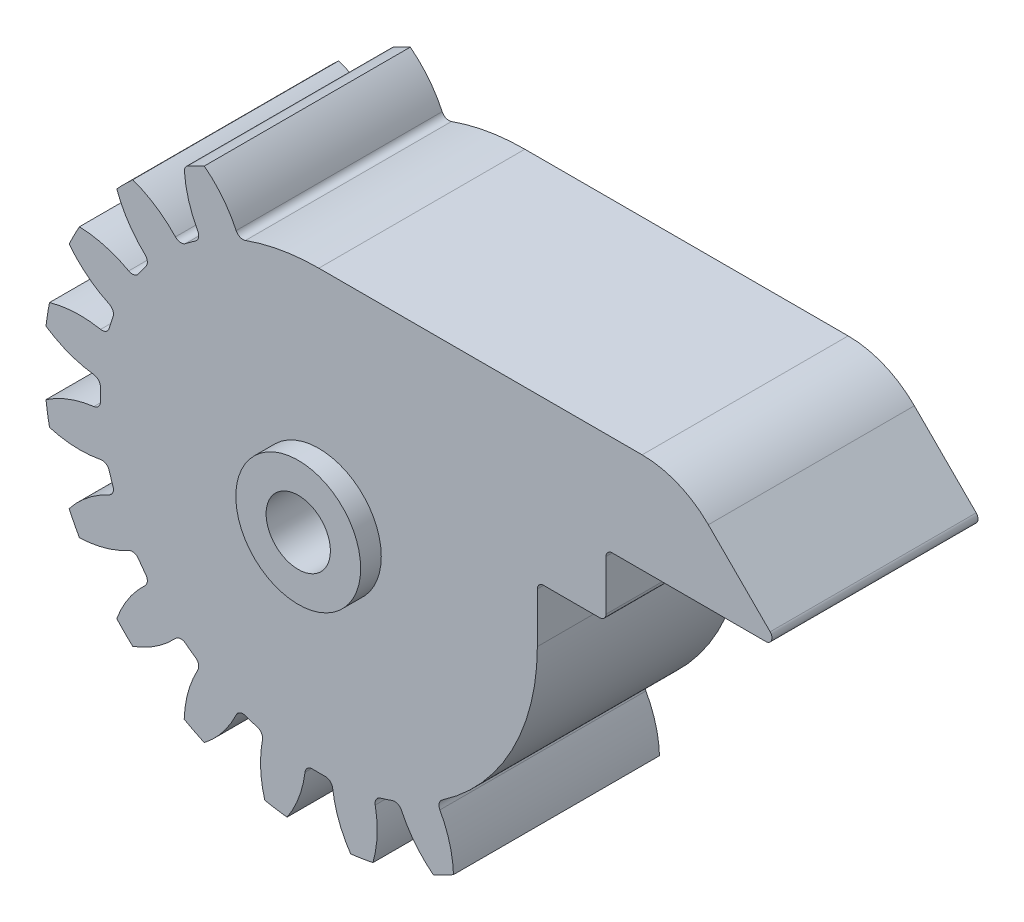
from build123d import *

# Parameters (mm, degrees)
SKBASE_R                                = 22
BASE_DEPTH                              = 8.25
TOOTHPROFILE_DEPTH                      = 9.25
FILLETTOOTHPROFILE_R                    = 0.6
CIRPATTERNTEETH_COUNT                   = 20
FILLETTOOTHPROFILE_OF_CIRPATTERNTEETH_R = 0.6
SKCHAVETA_R                             = 2.575
CHAVETA_DEPTH                           = 17.5000001
CUT_EXTRUDE1_DEPTH                      = 16.5
BOSS_EXTRUDE1_DEPTH                     = 16.5
FILLET3_R                               = 0.5
BOSS_EXTRUDE2_START                     = -16.5
SKETCH10_R                              = 5
SKETCH10_R_2                            = 2.575
BOSS_EXTRUDE2_DEPTH                     = 1.65
FILLET4_R                               = 7.5


with BuildPart() as part:
    # skBase → Base (new body, symmetric)
    with BuildSketch(Plane.XY):
        Circle(SKBASE_R)
    extrude(amount=BASE_DEPTH, both=True)

    # skToothProfile → ToothProfile (cut, symmetric)
    with BuildSketch(Plane.XY):
        with BuildLine():
            ThreePointArc((-1.056260379, 17.468094172), (-1.711312383, 20.303280592), (-3.25795804, 22.768085326))
            ThreePointArc((-3.25795804, 22.768085326), (0, 23), (3.25795804, 22.768085326))
            ThreePointArc((3.25795804, 22.768085326), (1.711312383, 20.303280592), (1.056260379, 17.468094172))
            ThreePointArc((1.056260379, 17.468094172), (0, 17.5), (-1.056260379, 17.468094172))
        make_face()
    toothprofile = extrude(amount=TOOTHPROFILE_DEPTH, both=True, mode=Mode.SUBTRACT)

    # FilletToothProfile
    fillettoothprofile_edges = [part.edges().sort_by_distance(p)[0] for p in [
        (-1.056260379, 17.468094172, 0),
        (1.056260379, 17.468094172, 0),
    ]]
    fillet(fillettoothprofile_edges, radius=FILLETTOOTHPROFILE_R)

    # CirPatternTeeth: ToothProfile ×20 about axis
    cirpatternteeth_axis = Axis((0, 0, 0), (0, 0, 1))
    for i in range(1, CIRPATTERNTEETH_COUNT):
        add(toothprofile.rotate(cirpatternteeth_axis, i * 360 / CIRPATTERNTEETH_COUNT), mode=Mode.SUBTRACT)

    # FilletToothProfile of CirPatternTeeth
    fillettoothprofile_of_cirpatternteeth_edges = [part.edges().sort_by_distance(p)[0] for p in [
        (-6.402501275, 16.286742382, 0),
        (-4.393374642, 16.939547198, 0),
        (-11.122020738, 13.511130771, 0),
        (-9.412955543, 14.752839318, 0),
        (-14.752839318, 9.412955543, 0),
        (-13.511130771, 11.122020738, 0),
        (-16.939547198, 4.393374642, 0),
        (-16.286742382, 6.402501275, 0),
        (-17.468094172, -1.056260379, 0),
        (-17.468094172, 1.056260379, 0),
        (-16.286742382, -6.402501275, 0),
        (-16.939547198, -4.393374642, 0),
        (-13.511130771, -11.122020738, 0),
        (-14.752839318, -9.412955543, 0),
        (-9.412955543, -14.752839318, 0),
        (-11.122020738, -13.511130771, 0),
        (-4.393374642, -16.939547198, 0),
        (-6.402501275, -16.286742382, 0),
        (1.056260379, -17.468094172, 0),
        (-1.056260379, -17.468094172, 0),
        (6.402501275, -16.286742382, 0),
        (4.393374642, -16.939547198, 0),
        (11.122020738, -13.511130771, 0),
        (9.412955543, -14.752839318, 0),
        (14.752839318, -9.412955543, 0),
        (13.511130771, -11.122020738, 0),
        (16.939547198, -4.393374642, 0),
        (16.286742382, -6.402501275, 0),
        (17.468094172, 1.056260379, 0),
        (17.468094172, -1.056260379, 0),
        (16.286742382, 6.402501275, 0),
        (16.939547198, 4.393374642, 0),
        (13.511130771, 11.122020738, 0),
        (14.752839318, 9.412955543, 0),
        (9.412955543, 14.752839318, 0),
        (11.122020738, 13.511130771, 0),
        (4.393374642, 16.939547198, 0),
        (6.402501275, 16.286742382, 0),
    ]]
    fillet(fillettoothprofile_of_cirpatternteeth_edges, radius=FILLETTOOTHPROFILE_OF_CIRPATTERNTEETH_R)

    # skChaveta → Chaveta (cut, through all)
    with BuildSketch(Plane.XY.offset(8.25)):
        Circle(SKCHAVETA_R)
    extrude(amount=-CHAVETA_DEPTH, mode=Mode.SUBTRACT)

    # Sketch7 → Cut-Extrude1 (cut)
    with BuildSketch(Plane(origin=(0, 0, -8.25), x_dir=(-1, 0, 0), z_dir=(0, 0, -1))):
        with BuildLine():
            ThreePointArc((-17.493007874, 0.494646854), (-17.28454596, 2.737603138), (-16.789693413, 4.935199602))
            ThreePointArc((-16.789693413, 4.935199602), (-17.05320753, 4.591987385), (-17.479060308, 4.515281924))
            ThreePointArc((-17.479060308, 4.515281924), (-19.535104209, 4.665405011), (-21.569390736, 4.331441248))
            ThreePointArc((-21.569390736, 4.331441248), (-21.729143493, 3.441558231), (-21.852198568, 2.545862871))
            ThreePointArc((-21.852198568, 2.545862871), (-20.020677589, 1.599615351), (-18.018873054, 1.107038384))
            ThreePointArc((-18.018873054, 1.107038384), (-17.637566285, 0.90249141), (-17.493007874, 0.494646854))
        make_face()
        with BuildLine():
            ThreePointArc((-17.479060308, -4.515281924), (-17.05320753, -4.591987385), (-16.789693413, -4.935199602))
            ThreePointArc((-16.789693413, -4.935199602), (-17.28454596, -2.737603138), (-17.493007874, -0.494646854))
            ThreePointArc((-17.493007874, -0.494646854), (-17.637566285, -0.90249141), (-18.018873054, -1.107038384))
            ThreePointArc((-18.018873054, -1.107038384), (-20.020677589, -1.599615351), (-21.852198568, -2.545862871))
            ThreePointArc((-21.852198568, -2.545862871), (-21.729143493, -3.441558231), (-21.569390736, -4.331441248))
            ThreePointArc((-21.569390736, -4.331441248), (-19.535104209, -4.665405011), (-17.479060308, -4.515281924))
        make_face()
        with BuildLine():
            ThreePointArc((-15.228275356, -9.695614978), (-14.799562005, -9.636970461), (-14.442886779, -9.881954336))
            ThreePointArc((-14.442886779, -9.881954336), (-15.592614173, -7.944833745), (-16.483984844, -5.87607383))
            ThreePointArc((-16.483984844, -5.87607383), (-16.495437164, -6.308628058), (-16.79487296, -6.620994062))
            ThreePointArc((-16.79487296, -6.620994062), (-18.546487554, -7.708054217), (-19.99596095, -9.173960195))
            ThreePointArc((-19.99596095, -9.173960195), (-19.602143532, -9.987790994), (-19.175220656, -10.78475372))
            ThreePointArc((-19.175220656, -10.78475372), (-17.137298721, -10.473743024), (-15.228275356, -9.695614978))
        make_face()
        with BuildLine():
            ThreePointArc((-16.483984844, 5.87607383), (-15.592614173, 7.944833745), (-14.442886779, 9.881954336))
            ThreePointArc((-14.442886779, 9.881954336), (-14.799562005, 9.636970461), (-15.228275356, 9.695614978))
            ThreePointArc((-15.228275356, 9.695614978), (-17.137298721, 10.473743024), (-19.175220656, 10.78475372))
            ThreePointArc((-19.175220656, 10.78475372), (-19.602143532, 9.987790994), (-19.99596095, 9.173960195))
            ThreePointArc((-19.99596095, 9.173960195), (-18.546487554, 7.708054217), (-16.79487296, 6.620994062))
            ThreePointArc((-16.79487296, 6.620994062), (-16.495437164, 6.308628058), (-16.483984844, 5.87607383))
        make_face()
        with BuildLine():
            ThreePointArc((-13.861394527, 10.682309758), (-12.374368671, 12.374368671), (-10.682309758, 13.861394527))
            ThreePointArc((-10.682309758, 13.861394527), (-11.097232237, 13.738619723), (-11.48684071, 13.926873684))
            ThreePointArc((-11.48684071, 13.926873684), (-13.061975031, 15.256838096), (-14.904046377, 16.182379355))
            ThreePointArc((-14.904046377, 16.182379355), (-15.556349186, 15.556349186), (-16.182379355, 14.904046377))
            ThreePointArc((-16.182379355, 14.904046377), (-15.256838096, 13.061975031), (-13.926873684, 11.48684071))
            ThreePointArc((-13.926873684, 11.48684071), (-13.738619723, 11.097232237), (-13.861394527, 10.682309758))
        make_face()
        with BuildLine():
            ThreePointArc((-9.881954336, 14.442886779), (-7.944833745, 15.592614173), (-5.87607383, 16.483984844))
            ThreePointArc((-5.87607383, 16.483984844), (-6.308628058, 16.495437164), (-6.620994062, 16.79487296))
            ThreePointArc((-6.620994062, 16.79487296), (-7.708054217, 18.546487554), (-9.173960195, 19.99596095))
            ThreePointArc((-9.173960195, 19.99596095), (-9.987790994, 19.602143532), (-10.78475372, 19.175220656))
            ThreePointArc((-10.78475372, 19.175220656), (-10.473743024, 17.137298721), (-9.695614978, 15.228275356))
            ThreePointArc((-9.695614978, 15.228275356), (-9.636970461, 14.799562005), (-9.881954336, 14.442886779))
        make_face()
        with BuildLine():
            ThreePointArc((-4.935199602, 16.789693413), (-2.737603138, 17.28454596), (-0.494646854, 17.493007874))
            ThreePointArc((-0.494646854, 17.493007874), (-0.90249141, 17.637566285), (-1.107038384, 18.018873054))
            ThreePointArc((-1.107038384, 18.018873054), (-1.599615351, 20.020677589), (-2.545862871, 21.852198568))
            ThreePointArc((-2.545862871, 21.852198568), (-3.441558231, 21.729143493), (-4.331441248, 21.569390736))
            ThreePointArc((-4.331441248, 21.569390736), (-4.665405011, 19.535104209), (-4.515281924, 17.479060308))
            ThreePointArc((-4.515281924, 17.479060308), (-4.591987385, 17.05320753), (-4.935199602, 16.789693413))
        make_face()
        with BuildLine():
            ThreePointArc((-11.48684071, -13.926873684), (-11.097232237, -13.738619723), (-10.682309758, -13.861394527))
            ThreePointArc((-10.682309758, -13.861394527), (-12.374368671, -12.374368671), (-13.861394527, -10.682309758))
            ThreePointArc((-13.861394527, -10.682309758), (-13.738619723, -11.097232237), (-13.926873684, -11.48684071))
            ThreePointArc((-13.926873684, -11.48684071), (-15.256838096, -13.061975031), (-16.182379355, -14.904046377))
            ThreePointArc((-16.182379355, -14.904046377), (-15.556349186, -15.556349186), (-14.904046377, -16.182379355))
            ThreePointArc((-14.904046377, -16.182379355), (-13.061975031, -15.256838096), (-11.48684071, -13.926873684))
        make_face()
        with BuildLine():
            ThreePointArc((0.494646854, 17.493007874), (2.737603138, 17.28454596), (4.935199602, 16.789693413))
            ThreePointArc((4.935199602, 16.789693413), (4.591987385, 17.05320753), (4.515281924, 17.479060308))
            ThreePointArc((4.515281924, 17.479060308), (4.665405011, 19.535104209), (4.331441248, 21.569390736))
            ThreePointArc((4.331441248, 21.569390736), (3.441558231, 21.729143493), (2.545862871, 21.852198568))
            ThreePointArc((2.545862871, 21.852198568), (1.599615351, 20.020677589), (1.107038384, 18.018873054))
            ThreePointArc((1.107038384, 18.018873054), (0.90249141, 17.637566285), (0.494646854, 17.493007874))
        make_face()
    extrude(amount=-CUT_EXTRUDE1_DEPTH, mode=Mode.SUBTRACT)

    # Sketch9 → Boss-Extrude1 (add)
    with BuildSketch(Plane(origin=(0, 0, -8.25), x_dir=(-1, 0, 0), z_dir=(0, 0, -1))):
        with BuildLine():
            Line((-37, 9.5), (-23, 9.5))
            Line((-23, 9.5), (-23, 4.5))
            Line((-23, 4.5), (-17.5, 4.5))
            Line((-17.5, 4.5), (-17.5, 0))
            ThreePointArc((-17.5, 0), (-12.374368671, 12.374368671), (0, 17.5))
            Line((0, 17.5), (-29, 17.5))
            Line((-29, 17.5), (-37, 9.5))
        make_face()
    extrude(amount=-BOSS_EXTRUDE1_DEPTH)

    # Fillet3
    fillet3_edges = [part.edges().sort_by_distance(p)[0] for p in [
        (-10.78475372, 19.175220656, 0),
        (17.5, 4.5, 0),
        (23, 4.5, 0),
        (23, 9.5, 0),
        (37, 9.5, 0),
    ]]
    fillet(fillet3_edges, radius=FILLET3_R)

    # Sketch10 → Boss-Extrude2 (add)
    with BuildSketch(Plane(origin=(0, 0, -8.25), x_dir=(-1, 0, 0), z_dir=(0, 0, -1)).offset(BOSS_EXTRUDE2_START)):
        Circle(SKETCH10_R)
        Circle(SKETCH10_R_2, mode=Mode.SUBTRACT)
    extrude(amount=-BOSS_EXTRUDE2_DEPTH)

    # Fillet4
    fillet4_edges = [part.edges().sort_by_distance(p)[0] for p in [
        (29, 17.5, 0),
    ]]
    fillet(fillet4_edges, radius=FILLET4_R)


solid = part.part
